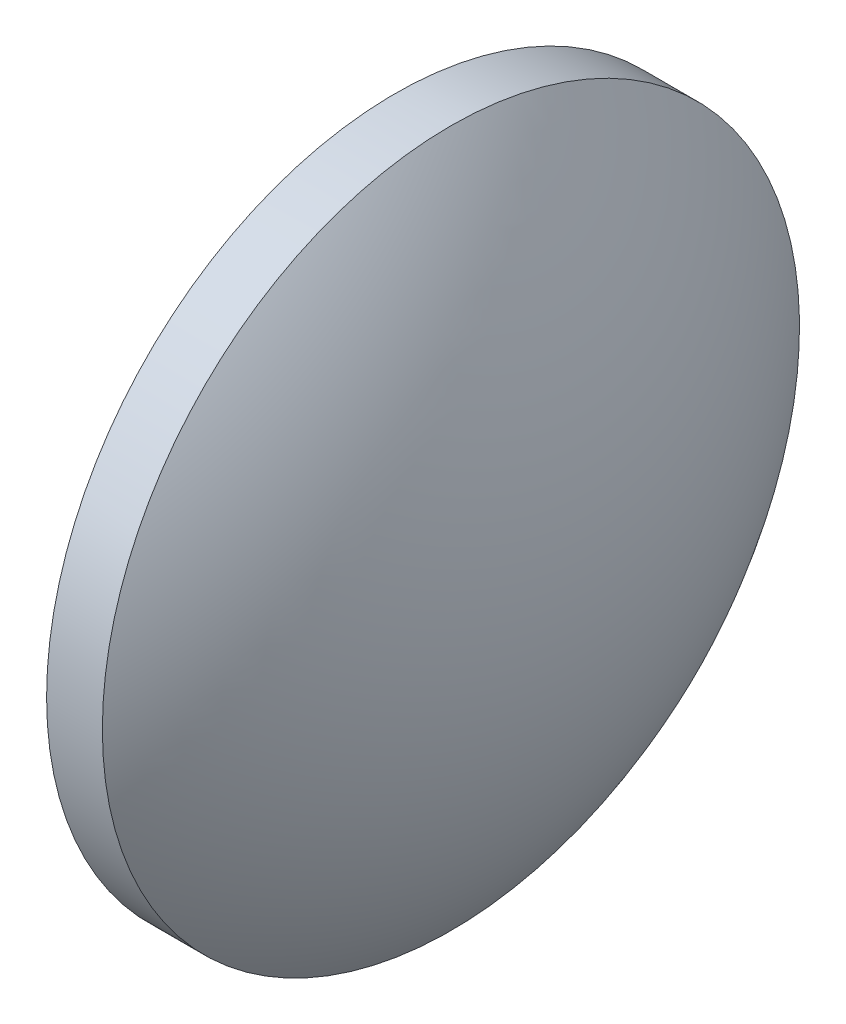
from build123d import *


with BuildPart() as part:
    # 草图1 → 旋转1 (revolve)
    with BuildSketch(Plane.XY):
        with BuildLine():
            Line((563.553588914, 156.072440309), (563.553588914, 168.572440309))
            Line((563.553588914, 168.572440309), (565.553588914, 168.572440309))
            ThreePointArc((565.553588914, 168.572440309), (568.682823155, 162.667402401), (569.763588914, 156.072440309))
            Line((569.763588914, 156.072440309), (563.553588914, 156.072440309))
        make_face()
    revolve(axis=Axis((562.041557672, 156.072440309, 0), (1, 0, 0)))


solid = part.part
